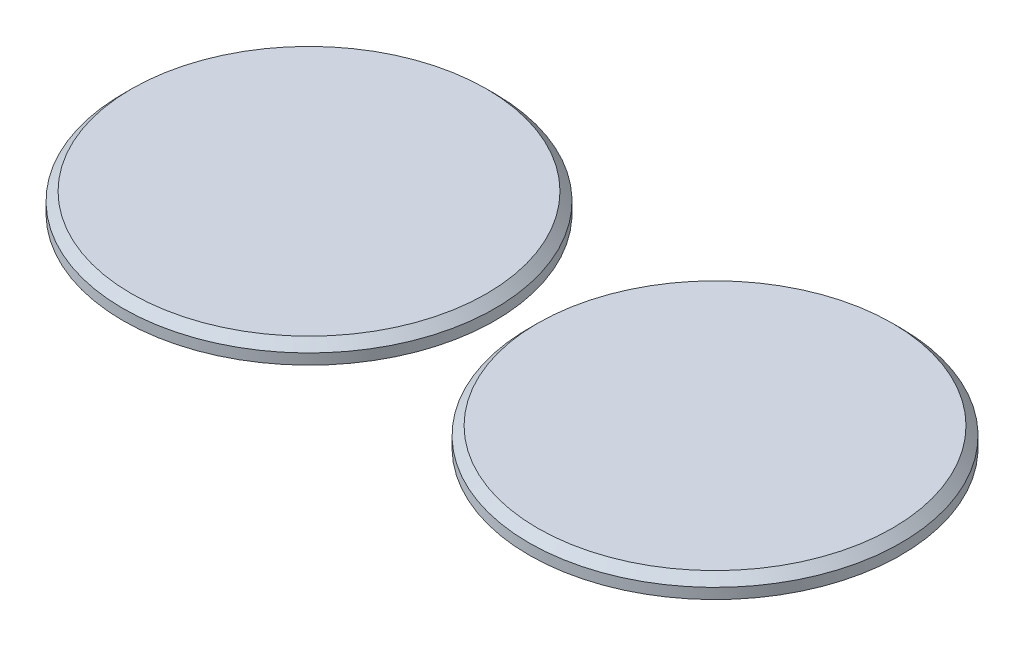
from build123d import *

# Parameters (mm, degrees)
SKETCH1_W                         = 152.4
SKETCH1_H                         = 84.074
STOCK_DEPTH                       = 3.302
SKETCH2_W                         = 152.4
SKETCH2_H                         = 84.074
SKETCH2_R                         = 27.3
DISKS_CLEAROUT_DEPTH              = 1
DISKS_CLEAROUT_DEPTH_BACK         = 4.302
DISK0_CHAM0_SIZE                  = 1.75
DISK1_CHAM1_SIZE                  = 1.75
SKETCH3_R                         = 27.3
TOPSURFACE_SURFACEPREP_DEPTH      = 1
TOPSURFACE_SURFACEPREP_DEPTH_BACK = 0.5


with BuildPart() as part:
    # Sketch1 → stock (new body)
    with BuildSketch(Plane(origin=(0, 0, 0), x_dir=(1, 0, 0), z_dir=(0, 1, 0))):
        with Locations((76.2, 42.037)):
            Rectangle(SKETCH1_W, SKETCH1_H)
    extrude(amount=STOCK_DEPTH)

    # Sketch2 → disks-clearout (cut, two sides)
    with BuildSketch(Plane(origin=(0, 3.302, 0), x_dir=(1, 0, 0), z_dir=(0, 1, 0))) as disks_clearout_sk:
        with Locations((76.2, 42.037)):
            Rectangle(SKETCH2_W, SKETCH2_H)
        with Locations((91.9, 32.3)):
            Circle(SKETCH2_R, mode=Mode.SUBTRACT)
        with Locations((32.3, 32.3)):
            Circle(SKETCH2_R, mode=Mode.SUBTRACT)
    extrude(amount=DISKS_CLEAROUT_DEPTH, mode=Mode.SUBTRACT)
    extrude(disks_clearout_sk.sketch, amount=-DISKS_CLEAROUT_DEPTH_BACK, mode=Mode.SUBTRACT)

    # disk0-cham0
    disk0_cham0_edges = [part.edges().sort_by_distance(p)[0] for p in [
        (5, 3.302, -32.3),
    ]]
    chamfer(disk0_cham0_edges, length=DISK0_CHAM0_SIZE)

    # disk1-cham1
    disk1_cham1_edges = [part.edges().sort_by_distance(p)[0] for p in [
        (64.6, 3.302, -32.3),
    ]]
    chamfer(disk1_cham1_edges, length=DISK1_CHAM1_SIZE)

    # Sketch3 → topsurface_surfaceprep (cut, two sides)
    with BuildSketch(Plane(origin=(0, 3.302, 0), x_dir=(1, 0, 0), z_dir=(0, 1, 0))) as topsurface_surfaceprep_sk:
        with Locations((32.3, 32.3)):
            Circle(SKETCH3_R)
        with Locations((91.9, 32.3)):
            Circle(SKETCH3_R)
    extrude(amount=TOPSURFACE_SURFACEPREP_DEPTH, mode=Mode.SUBTRACT)
    extrude(topsurface_surfaceprep_sk.sketch, amount=-TOPSURFACE_SURFACEPREP_DEPTH_BACK, mode=Mode.SUBTRACT)


solid = part.part
